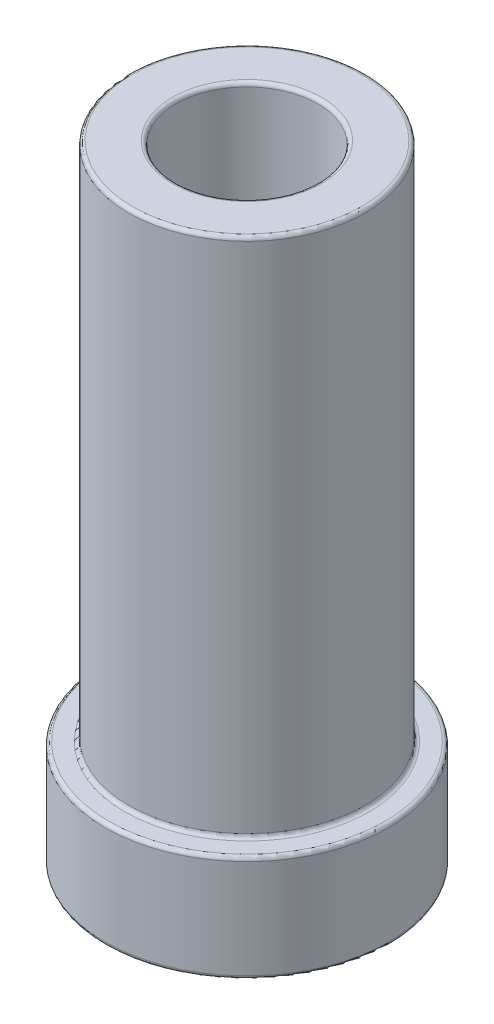
from build123d import *

# Parameters (mm, degrees)
SKETCH1_R           = 4.7625
SKETCH1_R_2         = 2.38125
BOSS_EXTRUDE1_DEPTH = 3.571875
SKETCH2_R           = 3.96875
SKETCH2_R_2         = 2.38125
BOSS_EXTRUDE2_DEPTH = 17.4625
FILLET1_R           = 0.127


with BuildPart() as part:
    # Sketch1 → Boss-Extrude1 (new body)
    with BuildSketch(Plane(origin=(0, 0, 0), x_dir=(1, 0, 0), z_dir=(0, 1, 0))):
        Circle(SKETCH1_R)
        Circle(SKETCH1_R_2, mode=Mode.SUBTRACT)
    extrude(amount=BOSS_EXTRUDE1_DEPTH)

    # Sketch2 → Boss-Extrude2 (add)
    with BuildSketch(Plane(origin=(0, 3.571875, 0), x_dir=(1, 0, 0), z_dir=(0, 1, 0))):
        Circle(SKETCH2_R)
        Circle(SKETCH2_R_2, mode=Mode.SUBTRACT)
    extrude(amount=BOSS_EXTRUDE2_DEPTH)

    # Fillet1
    fillet1_edges = [part.edges().sort_by_distance(p)[0] for p in [
        (-3.96875, 3.571875, 0),
        (-3.96875, 21.034375, 0),
        (-2.38125, 21.034375, 0),
        (-4.7625, 0, 0),
        (-4.7625, 3.571875, 0),
        (-2.38125, 0, 0),
    ]]
    fillet(fillet1_edges, radius=FILLET1_R)


solid = part.part
